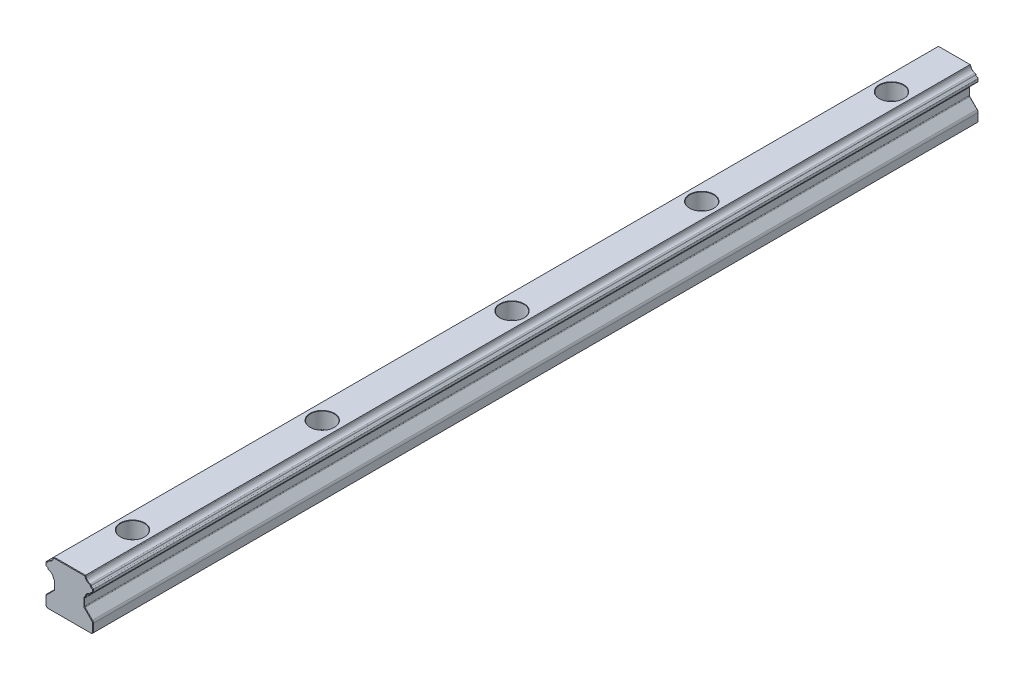
from build123d import *

# Parameters (mm, degrees)
BODY_DEPTH                                 = 280
AESTHETIC_CHAMFER_SIZE                     = 0.15
PRODUCTION_FILLET_R                        = 0.1
MOUNTING_HOLES_PATTERN_COUNT               = 5
MOUNTING_HOLES_PATTERN_PITCH               = 60
PRODUCTION_FILLET_OF_MOUNTING_HOLES_PATT_R = 0.1


with BuildPart() as part:
    # Rail Profile → Body (new body)
    with BuildSketch(Plane.XY):
        with BuildLine():
            Line((-7, 0), (7, 0))
            Line((7, 0), (7.5, 0.5))
            Line((7.5, 0.5), (7.5, 3.085786438))
            ThreePointArc((7.5, 3.085786438), (7.423879533, 3.46846987), (7.207106781, 3.792893219))
            Line((7.207106781, 3.792893219), (4.867157288, 6.132842712))
            ThreePointArc((4.867157288, 6.132842712), (4.780448187, 6.262612052), (4.75, 6.415685425))
            Line((4.75, 6.415685425), (4.75, 8.584314575))
            ThreePointArc((4.75, 8.584314575), (4.780448187, 8.737387948), (4.867157288, 8.867157288))
            Line((4.867157288, 8.867157288), (5.062965362, 9.062965362))
            ThreePointArc((5.062965362, 9.062965362), (5.134996734, 9.161242682), (5.17409812, 9.27664646))
            ThreePointArc((5.17409812, 9.27664646), (5.61862915, 10.13137085), (6.47335354, 10.57590188))
            ThreePointArc((6.47335354, 10.57590188), (6.694124352, 10.694306692), (6.801170165, 10.920803148))
            ThreePointArc((6.801170165, 10.920803148), (6.915305692, 11.154571658), (7.149074202, 11.268707185))
            ThreePointArc((7.149074202, 11.268707185), (7.399691242, 11.400760606), (7.5, 11.665685425))
            Line((7.5, 11.665685425), (7.5, 12.334314575))
            ThreePointArc((7.5, 12.334314575), (7.399691242, 12.599239394), (7.149074202, 12.731292815))
            ThreePointArc((7.149074202, 12.731292815), (6.915305692, 12.845428342), (6.801170165, 13.079196852))
            ThreePointArc((6.801170165, 13.079196852), (6.694124352, 13.305693308), (6.47335354, 13.42409812))
            ThreePointArc((6.47335354, 13.42409812), (5.61862915, 13.86862915), (5.17409812, 14.72335354))
            ThreePointArc((5.17409812, 14.72335354), (5.134996734, 14.838757318), (5.062965362, 14.937034638))
            Line((5.062965362, 14.937034638), (5, 15))
            Line((5, 15), (-5, 15))
            Line((-5, 15), (-5.062965362, 14.937034638))
            ThreePointArc((-5.062965362, 14.937034638), (-5.134996734, 14.838757318), (-5.17409812, 14.72335354))
            ThreePointArc((-5.17409812, 14.72335354), (-5.61862915, 13.86862915), (-6.47335354, 13.42409812))
            ThreePointArc((-6.47335354, 13.42409812), (-6.694124352, 13.305693308), (-6.801170165, 13.079196852))
            ThreePointArc((-6.801170165, 13.079196852), (-6.915305692, 12.845428342), (-7.149074202, 12.731292815))
            ThreePointArc((-7.149074202, 12.731292815), (-7.399691242, 12.599239394), (-7.5, 12.334314575))
            Line((-7.5, 12.334314575), (-7.5, 11.665685425))
            ThreePointArc((-7.5, 11.665685425), (-7.399691242, 11.400760606), (-7.149074202, 11.268707185))
            ThreePointArc((-7.149074202, 11.268707185), (-6.915305692, 11.154571658), (-6.801170165, 10.920803148))
            ThreePointArc((-6.801170165, 10.920803148), (-6.694124352, 10.694306692), (-6.47335354, 10.57590188))
            ThreePointArc((-6.47335354, 10.57590188), (-5.61862915, 10.13137085), (-5.17409812, 9.27664646))
            ThreePointArc((-5.17409812, 9.27664646), (-5.134996734, 9.161242682), (-5.062965362, 9.062965362))
            Line((-5.062965362, 9.062965362), (-4.867157288, 8.867157288))
            ThreePointArc((-4.867157288, 8.867157288), (-4.780448187, 8.737387948), (-4.75, 8.584314575))
            Line((-4.75, 8.584314575), (-4.75, 6.415685425))
            ThreePointArc((-4.75, 6.415685425), (-4.780448187, 6.262612052), (-4.867157288, 6.132842712))
            Line((-4.867157288, 6.132842712), (-7.207106781, 3.792893219))
            ThreePointArc((-7.207106781, 3.792893219), (-7.423879533, 3.46846987), (-7.5, 3.085786438))
            Line((-7.5, 3.085786438), (-7.5, 0.5))
            Line((-7.5, 0.5), (-7, 0))
        make_face()
    extrude(amount=-BODY_DEPTH)

    # Aesthetic Chamfer
    aesthetic_chamfer_edges = [part.edges().sort_by_distance(p)[0] for p in [
        (7.423879533, 3.46846987, -280),
        (-5.134996734, 9.161242682, -280),
        (-4.965061325, 8.965061325, -280),
        (-4.780448187, 8.737387948, -280),
        (-4.75, 7.5, -280),
        (-4.780448187, 6.262612052, -280),
        (-6.037132034, 4.962867966, -280),
        (-7.423879533, 3.46846987, -280),
        (-7.5, 1.792893219, -280),
        (-7.25, 0.25, -280),
        (0, 0, -280),
        (6.037132034, 4.962867966, -280),
        (4.780448187, 6.262612052, -280),
        (4.75, 7.5, -280),
        (4.780448187, 8.737387948, -280),
        (4.965061325, 8.965061325, -280),
        (5.134996734, 9.161242682, -280),
        (5.61862915, 10.13137085, -280),
        (6.694124352, 10.694306692, -280),
        (0, 0, 0),
        (-7.25, 0.25, 0),
        (-7.5, 1.792893219, 0),
        (-7.423879533, 3.46846987, 0),
        (-6.037132034, 4.962867966, 0),
        (-4.780448187, 6.262612052, 0),
        (6.915305692, 11.154571658, -280),
        (-4.75, 7.5, 0),
        (-4.780448187, 8.737387948, 0),
        (-4.965061325, 8.965061325, 0),
        (-5.134996734, 9.161242682, 0),
        (-5.61862915, 10.13137085, 0),
        (-6.694124352, 10.694306692, 0),
        (-6.915305692, 11.154571658, 0),
        (7.25, 0.25, -280),
        (7.399691242, 11.400760606, -280),
        (-7.399691242, 11.400760606, 0),
        (-7.5, 12, 0),
        (-7.399691242, 12.599239394, 0),
        (-6.915305692, 12.845428342, 0),
        (-6.694124352, 13.305693308, 0),
        (-5.61862915, 13.86862915, 0),
        (-5.134996734, 14.838757318, 0),
        (-5.031482681, 14.968517319, 0),
        (7.5, 12, -280),
        (0, 15, 0),
        (5.031482681, 14.968517319, 0),
        (5.134996734, 14.838757318, 0),
        (5.61862915, 13.86862915, 0),
        (6.694124352, 13.305693308, 0),
        (6.915305692, 12.845428342, 0),
        (7.399691242, 12.599239394, 0),
        (7.399691242, 12.599239394, -280),
        (7.5, 12, 0),
        (7.399691242, 11.400760606, 0),
        (6.915305692, 11.154571658, 0),
        (6.694124352, 10.694306692, 0),
        (5.61862915, 10.13137085, 0),
        (5.134996734, 9.161242682, 0),
        (4.965061325, 8.965061325, 0),
        (4.780448187, 8.737387948, 0),
        (6.915305692, 12.845428342, -280),
        (4.75, 7.5, 0),
        (4.780448187, 6.262612052, 0),
        (6.037132034, 4.962867966, 0),
        (7.423879533, 3.46846987, 0),
        (7.5, 1.792893219, 0),
        (7.25, 0.25, 0),
        (6.694124352, 13.305693308, -280),
        (5.61862915, 13.86862915, -280),
        (5.134996734, 14.838757318, -280),
        (5.031482681, 14.968517319, -280),
        (0, 15, -280),
        (-5.031482681, 14.968517319, -280),
        (7.5, 1.792893219, -280),
        (-5.134996734, 14.838757318, -280),
        (-5.61862915, 13.86862915, -280),
        (-6.694124352, 13.305693308, -280),
        (-6.915305692, 12.845428342, -280),
        (-7.399691242, 12.599239394, -280),
        (-7.5, 12, -280),
        (-7.399691242, 11.400760606, -280),
        (-6.915305692, 11.154571658, -280),
        (-6.694124352, 10.694306692, -280),
        (-5.61862915, 10.13137085, -280),
    ]]
    chamfer(aesthetic_chamfer_edges, length=AESTHETIC_CHAMFER_SIZE)

    # Sketch1 → Mounting Hole (revolve, cut)
    with BuildSketch(Plane(origin=(0, 15, -20), x_dir=(0, 0, 1), z_dir=(1, 0, 0))):
        Polygon((0, 0), (0, 15), (2.35, 15), (2.25, 14.9), (2.25, 5.4), (2.35, 5.3), (3.75, 5.3), (3.75, 0.1), (3.85, 0), align=None)
    mounting_hole = revolve(axis=Axis((0, 21.35, -20), (0, -1, 0)), mode=Mode.SUBTRACT)

    # Production Fillet
    production_fillet_edges = [part.edges().sort_by_distance(p)[0] for p in [
        (0, 9.7, -23.75),
    ]]
    fillet(production_fillet_edges, radius=PRODUCTION_FILLET_R)

    # Mounting Holes Pattern: Mounting Hole ×5
    with Locations(*[(0, 0, -i * MOUNTING_HOLES_PATTERN_PITCH) for i in range(1, MOUNTING_HOLES_PATTERN_COUNT)]):
        add(mounting_hole, mode=Mode.SUBTRACT)

    # Production Fillet of Mounting Holes Patt
    production_fillet_of_mounting_holes_patt_edges = [part.edges().sort_by_distance(p)[0] for p in [
        (0, 9.7, -83.75),
        (0, 9.7, -143.75),
        (0, 9.7, -203.75),
        (0, 9.7, -263.75),
    ]]
    fillet(production_fillet_of_mounting_holes_patt_edges, radius=PRODUCTION_FILLET_OF_MOUNTING_HOLES_PATT_R)


solid = part.part
